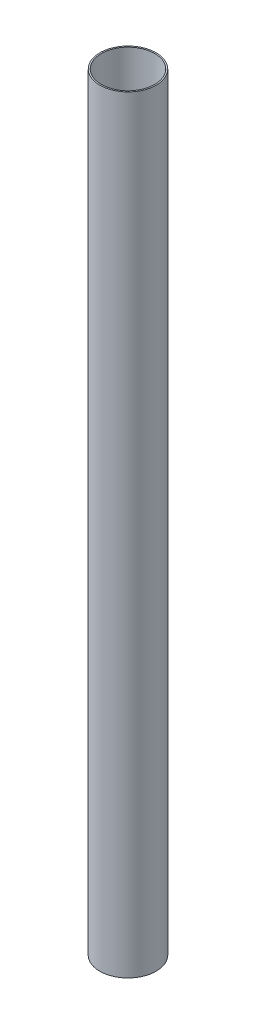
from build123d import *

# Parameters (mm, degrees)
SKETCH_2_R      = 55
SKETCH_2_R_2    = 52.3
EXTRUDE_1_DEPTH = 1500


with BuildPart() as part:
    # Эскиз2 → Вытянуть-Тонкостенный1 (new body)
    with BuildSketch(Plane(origin=(0, 0, 0), x_dir=(1, 0, 0), z_dir=(0, 1, 0))):
        Circle(SKETCH_2_R)
        Circle(SKETCH_2_R_2, mode=Mode.SUBTRACT)
    extrude(amount=EXTRUDE_1_DEPTH)


solid = part.part
